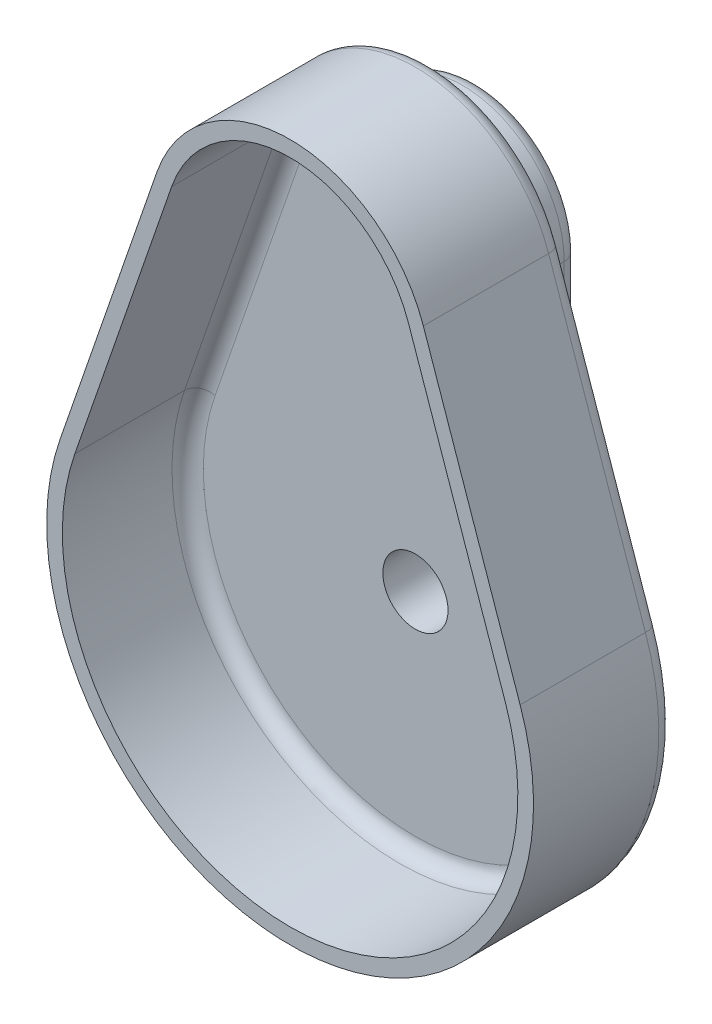
from build123d import *

# Parameters (mm, degrees)
SKETCH1_R           = 3.302
BOSS_EXTRUDE1_DEPTH = 6.35
BOSS_EXTRUDE2_START = -6.35
SKETCH2_R           = 3.302
BOSS_EXTRUDE2_DEPTH = 1.5875
BOSS_EXTRUDE3_DEPTH = 12.7
FILLET1_R           = 1.5875
FILLET2_R           = 1.5875


with BuildPart() as part:
    # Sketch1 → Boss-Extrude1 (new body)
    with BuildSketch(Plane.XY):
        with BuildLine():
            Line((10.31875, 31.75), (10.31875, 0))
            ThreePointArc((10.31875, 0), (0, -10.31875), (-10.31875, 0))
            Line((-10.31875, 0), (-10.31875, 31.75))
            ThreePointArc((-10.31875, 31.75), (0, 42.06875), (10.31875, 31.75))
        make_face()
        Circle(SKETCH1_R, mode=Mode.SUBTRACT)
        with Locations((0, 31.75)):
            Circle(SKETCH1_R, mode=Mode.SUBTRACT)
    extrude(amount=BOSS_EXTRUDE1_DEPTH)

    # Sketch2 → Boss-Extrude2 (add)
    with BuildSketch(Plane(origin=(0, 0, 0), x_dir=(-1, 0, 0), z_dir=(0, 0, -1)).offset(BOSS_EXTRUDE2_START)):
        with BuildLine():
            Line((-23.31351417, 8.06700825), (-13.502035234, 36.4220125))
            ThreePointArc((-13.502035234, 36.4220125), (0, 46.0375), (13.502035234, 36.4220125))
            Line((13.502035234, 36.4220125), (23.31351417, 8.06700825))
            ThreePointArc((23.31351417, 8.06700825), (0, -24.66975), (-23.31351417, 8.06700825))
        make_face()
        Circle(SKETCH2_R, mode=Mode.SUBTRACT)
        with Locations((0, 31.75)):
            Circle(SKETCH2_R, mode=Mode.SUBTRACT)
    extrude(amount=BOSS_EXTRUDE2_DEPTH)

    # Sketch3 → Boss-Extrude3 (add)
    with BuildSketch(Plane.XY.offset(6.35)):
        with BuildLine():
            Line((-13.502035234, 36.4220125), (-23.31351417, 8.06700825))
            ThreePointArc((-23.31351417, 8.06700825), (0, -24.66975), (23.31351417, 8.06700825))
            Line((23.31351417, 8.06700825), (13.502035234, 36.4220125))
            ThreePointArc((13.502035234, 36.4220125), (0, 46.0375), (-13.502035234, 36.4220125))
        make_face()
        with BuildLine():
            Line((21.813288033, 7.54789575), (12.001809097, 35.9029))
            ThreePointArc((12.001809097, 35.9029), (0, 44.45), (-12.001809097, 35.9029))
            Line((-12.001809097, 35.9029), (-21.813288033, 7.54789575))
            ThreePointArc((-21.813288033, 7.54789575), (0, -23.08225), (21.813288033, 7.54789575))
        make_face(mode=Mode.SUBTRACT)
    extrude(amount=BOSS_EXTRUDE3_DEPTH)

    # Fillet1
    fillet1_edges = [part.edges().sort_by_distance(p)[0] for p in [
        (10.31875, 15.875, 4.7625),
        (0, 42.06875, 4.7625),
        (-10.31875, 15.875, 4.7625),
        (0, -10.31875, 4.7625),
        (0, 46.0375, 4.7625),
        (18.407774702, 22.244510375, 4.7625),
        (0, -24.66975, 4.7625),
        (-18.407774702, 22.244510375, 4.7625),
        (0, -23.08225, 6.35),
        (16.907548565, 21.725397875, 6.35),
        (0, 44.45, 6.35),
        (-16.907548565, 21.725397875, 6.35),
    ]]
    fillet(fillet1_edges, radius=FILLET1_R)

    # Fillet2
    fillet2_edges = [part.edges().sort_by_distance(p)[0] for p in [
        (10.31875, 15.875, 0),
        (0, -10.31875, 0),
        (-10.31875, 15.875, 0),
        (0, 42.06875, 0),
    ]]
    fillet(fillet2_edges, radius=FILLET2_R)


solid = part.part
